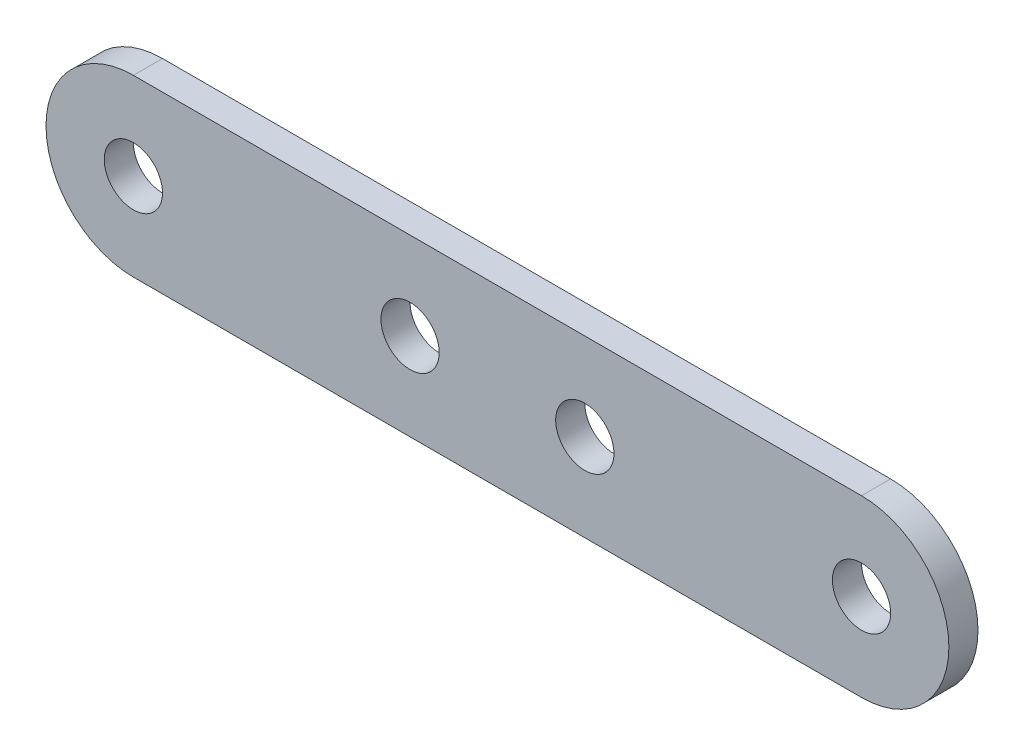
from build123d import *

# Parameters (mm, degrees)
ESQUISSE1_R        = 2
BOSS_EXTRU_1_DEPTH = 2


with BuildPart() as part:
    # Esquisse1 → Boss.-Extru.1 (new body)
    with BuildSketch(Plane.XY):
        with BuildLine():
            Line((6, -12), (56, -12))
            ThreePointArc((56, -12), (62, -6), (56, 0))
            Line((56, 0), (6, 0))
            ThreePointArc((6, 0), (0, -6), (6, -12))
        make_face()
        with Locations((6, -6)):
            Circle(ESQUISSE1_R, mode=Mode.SUBTRACT)
        with Locations((25, -6)):
            Circle(ESQUISSE1_R, mode=Mode.SUBTRACT)
        with Locations((37, -6)):
            Circle(ESQUISSE1_R, mode=Mode.SUBTRACT)
        with Locations((56, -6)):
            Circle(ESQUISSE1_R, mode=Mode.SUBTRACT)
    extrude(amount=-BOSS_EXTRU_1_DEPTH)


solid = part.part
